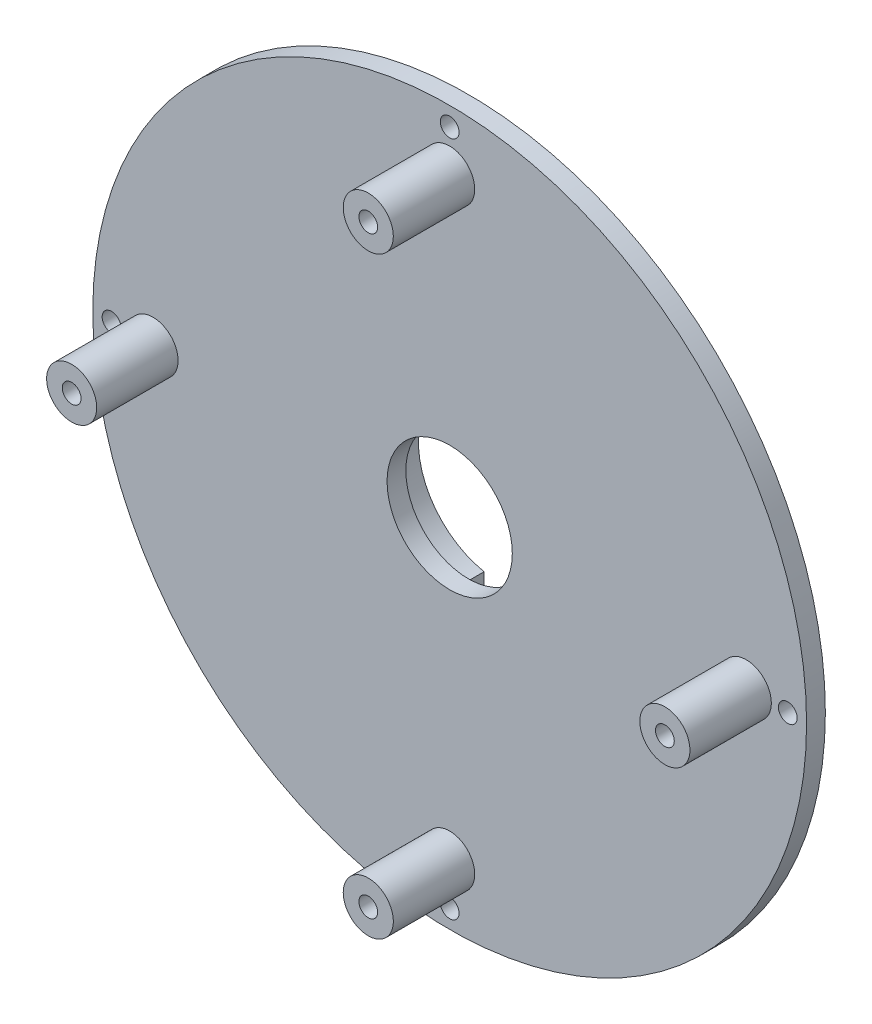
from build123d import *

# Parameters (mm, degrees)
SKETCH1_R           = 57
BOSS_EXTRUDE1_DEPTH = 3
SKETCH2_R           = 15
BOSS_EXTRUDE2_DEPTH = 5
SKETCH3_R           = 13
CUT_EXTRUDE1_DEPTH  = 5
SKETCH4_R           = 10
CUT_EXTRUDE2_DEPTH  = 3
SKETCH6_W           = 5
SKETCH6_H           = 50
CUT_EXTRUDE4_DEPTH  = 5
SKETCH8_R           = 1.5
CUT_EXTRUDE5_DEPTH  = 3
SKETCH9_R           = 4
BOSS_EXTRUDE4_DEPTH = 13
SKETCH11_R          = 1.5
CUT_EXTRUDE6_DEPTH  = 13
CIRPATTERN1_COUNT   = 4


with BuildPart() as part:
    # Sketch1 → Boss-Extrude1 (new body)
    with BuildSketch(Plane.XY):
        Circle(SKETCH1_R)
    extrude(amount=BOSS_EXTRUDE1_DEPTH)

    # Sketch2 → Boss-Extrude2 (add)
    with BuildSketch(Plane(origin=(0, 0, 0), x_dir=(-1, 0, 0), z_dir=(0, 0, -1))):
        Circle(SKETCH2_R)
    extrude(amount=BOSS_EXTRUDE2_DEPTH)

    # Sketch3 → Cut-Extrude1 (cut)
    with BuildSketch(Plane(origin=(0, 0, -5), x_dir=(-1, 0, 0), z_dir=(0, 0, -1))):
        Circle(SKETCH3_R)
    extrude(amount=-CUT_EXTRUDE1_DEPTH, mode=Mode.SUBTRACT)

    # Sketch4 → Cut-Extrude2 (cut)
    with BuildSketch(Plane(origin=(0, 0, 0), x_dir=(-1, 0, 0), z_dir=(0, 0, -1))):
        Circle(SKETCH4_R)
    extrude(amount=-CUT_EXTRUDE2_DEPTH, mode=Mode.SUBTRACT)

    # Sketch6 → Cut-Extrude4 (cut)
    with BuildSketch(Plane(origin=(0, 0, -5), x_dir=(-1, 0, 0), z_dir=(0, 0, -1))):
        Rectangle(SKETCH6_W, SKETCH6_H)
    extrude(amount=-CUT_EXTRUDE4_DEPTH, mode=Mode.SUBTRACT)

    # Sketch8 → Cut-Extrude5 (cut)
    with BuildSketch(Plane(origin=(0, 0, 0), x_dir=(-1, 0, 0), z_dir=(0, 0, -1))):
        with Locations((0, 54)):
            Circle(SKETCH8_R)
        with Locations((54, 0)):
            Circle(SKETCH8_R)
        with Locations((0, -54)):
            Circle(SKETCH8_R)
        with Locations((-54, 0)):
            Circle(SKETCH8_R)
    extrude(amount=-CUT_EXTRUDE5_DEPTH, mode=Mode.SUBTRACT)

    # Sketch9 → Boss-Extrude4 (add)
    with BuildSketch(Plane.XY.offset(3)):
        with Locations((0, 47.37)):
            Circle(SKETCH9_R)
    boss_extrude4 = extrude(amount=BOSS_EXTRUDE4_DEPTH)

    # Sketch11 → Cut-Extrude6 (cut)
    with BuildSketch(Plane.XY.offset(16)):
        with Locations((0, 47.37)):
            Circle(SKETCH11_R)
    cut_extrude6 = extrude(amount=-CUT_EXTRUDE6_DEPTH, mode=Mode.SUBTRACT)

    # CirPattern1: Boss-Extrude4, Cut-Extrude6 ×4 about axis
    cirpattern1_axis = Axis((0, 0, 0), (0, 0, 1))
    for i in range(1, CIRPATTERN1_COUNT):
        add(boss_extrude4.rotate(cirpattern1_axis, i * 360 / CIRPATTERN1_COUNT))
        add(cut_extrude6.rotate(cirpattern1_axis, i * 360 / CIRPATTERN1_COUNT), mode=Mode.SUBTRACT)


solid = part.part
